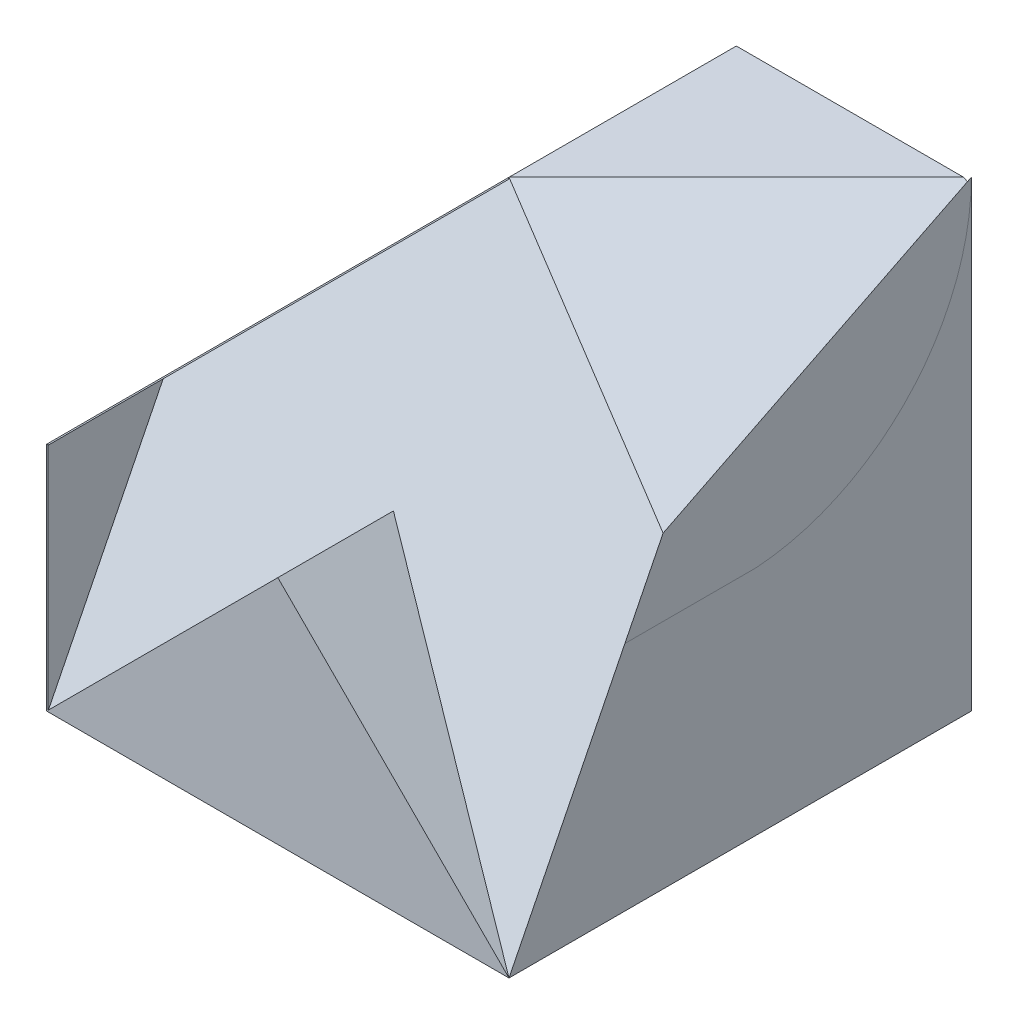
from build123d import *

# Parameters (mm, degrees)
SKETCH1_W            = 60
SKETCH1_H            = 60
BOSS_EXTRUDE1_DEPTH  = 60
CUT_EXTRUDE1_DEPTH   = 60
CUT_EXTRUDE2_DEPTH   = 60
CUT_EXTRUDE3_DEPTH   = 60
CUT_EXTRUDE4_DEPTH   = 60
CUT_EXTRUDE5_DEPTH   = 60
CUT_EXTRUDE6_DEPTH   = 60
CUT_EXTRUDE7_DEPTH   = 60
CUT_EXTRUDE8_DEPTH   = 60
BOSS_EXTRUDE3_DEPTH  = 60
BOSS_EXTRUDE7_DEPTH  = 0.15
BOSS_EXTRUDE8_DEPTH  = 0.15
CUT_EXTRUDE10_DEPTH  = 0.5
BOSS_EXTRUDE10_DEPTH = 0.0001


with BuildPart() as part:
    # Sketch1 → Boss-Extrude1 (new body)
    with BuildSketch(Plane.XY):
        with Locations((30, 30)):
            Rectangle(SKETCH1_W, SKETCH1_H)
    extrude(amount=BOSS_EXTRUDE1_DEPTH)

    # Sketch2 → Cut-Extrude1 (cut)
    with BuildSketch(Plane.XY.offset(60)):
        Polygon((30, 60), (0, 30), (0, 60), align=None)
    extrude(amount=-CUT_EXTRUDE1_DEPTH, mode=Mode.SUBTRACT)

    # Sketch3 → Cut-Extrude2 (cut)
    with BuildSketch(Plane(origin=(60, 0, 0), x_dir=(0, 0, -1), z_dir=(1, 0, 0))):
        Polygon((-60, 30), (-30, 60), (-60, 60), align=None)
    extrude(amount=-CUT_EXTRUDE2_DEPTH, mode=Mode.SUBTRACT)

    # Sketch4 → Cut-Extrude3 (cut)
    with BuildSketch(Plane(origin=(30, 60, 30), x_dir=(0.912870929, -0.365148372, -0.182574186), z_dir=(0.40824829, 0.816496581, 0.40824829))):
        Polygon((0, 0), (32.86335345, 26.83281573), (32.86335345, -40.249223595), align=None)
    extrude(amount=CUT_EXTRUDE3_DEPTH, mode=Mode.SUBTRACT)

    # Sketch5 → Cut-Extrude4 (cut)
    with BuildSketch(Plane(origin=(0, 24, 48), x_dir=(1, 0, 0), z_dir=(0, 0.447213595, 0.894427191))):
        Polygon((0, -26.83281573), (60, -26.83281573), (30, 40.249223595), align=None)
    extrude(amount=CUT_EXTRUDE4_DEPTH, mode=Mode.SUBTRACT)

    # Sketch6 → Cut-Extrude5 (cut)
    with BuildSketch(Plane(origin=(10, -4, 2), x_dir=(0.169515876, -0.06780635, -0.98319208), z_dir=(0.912870929, -0.365148372, 0.182574186))):
        Polygon((-58.991524815, 32.310988843), (-58.991524815, 0), (-28.478667152, 66.850321744), align=None)
    extrude(amount=-CUT_EXTRUDE5_DEPTH, mode=Mode.SUBTRACT)

    # Sketch7 → Cut-Extrude6 (cut)
    with BuildSketch(Plane(origin=(40, 16, -8), x_dir=(0.169515876, 0.06780635, 0.98319208), z_dir=(-0.912870929, -0.365148372, 0.182574186))):
        Polygon((38.649619706, 44.566881162), (69.162477369, -22.283440581), (69.162477369, 10.027548262), align=None)
    extrude(amount=-CUT_EXTRUDE6_DEPTH, mode=Mode.SUBTRACT)

    # Sketch8 → Cut-Extrude7 (cut)
    with BuildSketch(Plane(origin=(11.724137931, 4.689655172, 68), x_dir=(-0.985527457, 0.011663047, 0.169114179), z_dir=(-0.169515876, -0.06780635, -0.98319208))):
        Polygon((-36.808575777, 25.800784356), (-47.082262149, 27.800345143), (-48.984796662, 27.017107047), (-48.984796662, -4.128125497), align=None)
    extrude(amount=-CUT_EXTRUDE7_DEPTH, mode=Mode.SUBTRACT)

    # Sketch9 → Cut-Extrude8 (cut)
    with BuildSketch(Plane(origin=(-10, 4, 58), x_dir=(-0.985527457, -0.011663047, -0.169114179), z_dir=(0.169515876, -0.06780635, -0.98319208))):
        Polygon((-10.146850737, -4.128125497), (-10.146850737, 25.943133511), (-12.04938525, 27.800345143), (-22.323071622, 25.800784356), align=None)
    extrude(amount=-CUT_EXTRUDE8_DEPTH, mode=Mode.SUBTRACT)

    # Sketch11 → Boss-Extrude3 (add)
    with BuildSketch(Plane.XY.offset(60)):
        Polygon((0, 0), (30, 30), (60, 0), align=None)
    extrude(amount=-BOSS_EXTRUDE3_DEPTH)

    # Sketch12 → Boss-Extrude7 (add)
    with BuildSketch(Plane.ZY):
        Polygon((45, 30), (60, 0), (60, 30), align=None)
    extrude(amount=-BOSS_EXTRUDE7_DEPTH)

    # Sketch13 → Boss-Extrude8 (add)
    with BuildSketch(Plane(origin=(-15, 15, 0), x_dir=(0.707106781, 0.707106781, 0), z_dir=(-0.707106781, 0.707106781, 0))):
        Polygon((63.639610307, -30), (21.213203436, -60), (21.213203436, -45), align=None)
    extrude(amount=-BOSS_EXTRUDE8_DEPTH)

    # Sketch14 → Cut-Extrude10 (cut)
    with BuildSketch(Plane(origin=(0, 0, 0), x_dir=(-1, 0, 0), z_dir=(0, 0, -1))):
        with BuildLine():
            Line((-30, 30), (0, 30))
            Line((0, 30), (-30, 60))
            Line((-30, 60), (-60, 60))
            ThreePointArc((-60, 60), (-51.213203436, 38.786796564), (-30, 30))
        make_face()
    extrude(amount=-CUT_EXTRUDE10_DEPTH, mode=Mode.SUBTRACT)

    # Sketch15 → Boss-Extrude10 (add)
    with BuildSketch(Plane(origin=(60, 0, 0), x_dir=(0, 0, -1), z_dir=(1, 0, 0))):
        with BuildLine():
            Line((-27.89036592, 30.074267861), (-44.962866069, 30.074267861))
            Line((-44.962866069, 30.074267861), (-40, 40))
            Line((-40, 40), (0, 60))
            ThreePointArc((0, 60), (-8.053599129, 39.546259784), (-27.89036592, 30.074267861))
        make_face()
    extrude(amount=BOSS_EXTRUDE10_DEPTH)


solid = part.part
